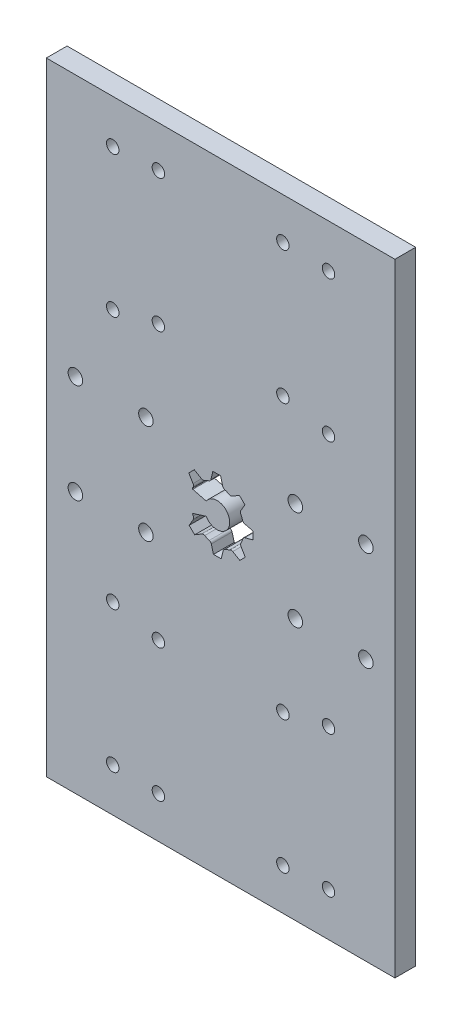
from build123d import *

# Parameters (mm, degrees)
CROQUIS1_W              = 84
CROQUIS1_H              = 150
CROQUIS1_R              = 1.5
CROQUIS1_R_2            = 1.75
SALIENTE_EXTRUIR1_DEPTH = 5


with BuildPart() as part:
    # Croquis1 → Saliente-Extruir1 (new body)
    with BuildSketch(Plane.XY):
        with Locations((42, 75)):
            Rectangle(CROQUIS1_W, CROQUIS1_H)
        with Locations((27, 108)):
            Circle(CROQUIS1_R, mode=Mode.SUBTRACT)
        with Locations((57, 108)):
            Circle(CROQUIS1_R, mode=Mode.SUBTRACT)
        with Locations((16, 139.5)):
            Circle(CROQUIS1_R, mode=Mode.SUBTRACT)
        with Locations((16, 105.5)):
            Circle(CROQUIS1_R, mode=Mode.SUBTRACT)
        with Locations((68, 105.5)):
            Circle(CROQUIS1_R, mode=Mode.SUBTRACT)
        with Locations((68, 139.5)):
            Circle(CROQUIS1_R, mode=Mode.SUBTRACT)
        with Locations((68, 44.5)):
            Circle(CROQUIS1_R, mode=Mode.SUBTRACT)
        with Locations((68, 10.5)):
            Circle(CROQUIS1_R, mode=Mode.SUBTRACT)
        with Locations((16, 10.5)):
            Circle(CROQUIS1_R, mode=Mode.SUBTRACT)
        with Locations((16, 44.5)):
            Circle(CROQUIS1_R, mode=Mode.SUBTRACT)
        with Locations((7, 87)):
            Circle(CROQUIS1_R_2, mode=Mode.SUBTRACT)
        with Locations((24, 87)):
            Circle(CROQUIS1_R_2, mode=Mode.SUBTRACT)
        with Locations((24, 63)):
            Circle(CROQUIS1_R_2, mode=Mode.SUBTRACT)
        with Locations((7, 63)):
            Circle(CROQUIS1_R_2, mode=Mode.SUBTRACT)
        with Locations((60, 63)):
            Circle(CROQUIS1_R_2, mode=Mode.SUBTRACT)
        with Locations((60, 87)):
            Circle(CROQUIS1_R_2, mode=Mode.SUBTRACT)
        with Locations((77, 63)):
            Circle(CROQUIS1_R_2, mode=Mode.SUBTRACT)
        with Locations((77, 87)):
            Circle(CROQUIS1_R_2, mode=Mode.SUBTRACT)
        with Locations((27, 140)):
            Circle(CROQUIS1_R, mode=Mode.SUBTRACT)
        with Locations((57, 140)):
            Circle(CROQUIS1_R, mode=Mode.SUBTRACT)
        with Locations((57, 42)):
            Circle(CROQUIS1_R, mode=Mode.SUBTRACT)
        with Locations((27, 42)):
            Circle(CROQUIS1_R, mode=Mode.SUBTRACT)
        with Locations((57, 10)):
            Circle(CROQUIS1_R, mode=Mode.SUBTRACT)
        with Locations((27, 10)):
            Circle(CROQUIS1_R, mode=Mode.SUBTRACT)
        with BuildLine():
            Line((34.323343601, 80.561599107), (35.636741331, 81.897273116))
            Line((35.636741331, 81.897273116), (37.36006695, 80.894327587))
            ThreePointArc((37.36006695, 80.894327587), (37.710271658, 80.796713171), (38.063524454, 80.882645547))
            ThreePointArc((38.063524454, 80.882645547), (38.605161451, 81.142605955), (39.168546725, 81.351285335))
            ThreePointArc((39.168546725, 81.351285335), (39.475874806, 81.545505215), (39.649132657, 81.865120028))
            Line((39.649132657, 81.865120028), (40.126027071, 83.80117856))
            Line((40.126027071, 83.80117856), (41.999203662, 83.816930268))
            Line((41.999203662, 83.816930268), (42.508589309, 81.889165452))
            ThreePointArc((42.508589309, 81.889165452), (42.687197617, 81.572509513), (42.99774843, 81.38348543))
            ThreePointArc((42.99774843, 81.38348543), (43.564563391, 81.184310005), (44.110495542, 80.933495061))
            ThreePointArc((44.110495542, 80.933495061), (44.465143507, 80.853515486), (44.81365711, 80.957005486))
            Line((44.81365711, 80.957005486), (46.519872501, 81.988790329))
            Line((46.519872501, 81.988790329), (47.85554651, 80.675392598))
            Line((47.85554651, 80.675392598), (46.852600981, 78.952066979))
            ThreePointArc((46.852600981, 78.952066979), (46.754986565, 78.601862272), (46.840918941, 78.248609475))
            ThreePointArc((46.840918941, 78.248609475), (47.10087935, 77.706972479), (47.309558729, 77.143587205))
            ThreePointArc((47.309558729, 77.143587205), (47.503778609, 76.836259124), (47.823393422, 76.663001273))
            Line((47.823393422, 76.663001273), (49.759451954, 76.186106858))
            Line((49.759451954, 76.186106858), (49.775203662, 74.312930268))
            Line((49.775203662, 74.312930268), (47.847438846, 73.803544621))
            ThreePointArc((47.847438846, 73.803544621), (47.530782907, 73.624936313), (47.341758824, 73.3143855))
            ThreePointArc((47.341758824, 73.3143855), (47.142583399, 72.747570539), (46.891768456, 72.201638387))
            ThreePointArc((46.891768456, 72.201638387), (46.81178888, 71.846990422), (46.91527888, 71.49847682))
            Line((46.91527888, 71.49847682), (47.947063723, 69.792261428))
            Line((47.947063723, 69.792261428), (46.633665992, 68.456587419))
            Line((46.633665992, 68.456587419), (44.910340373, 69.459532948))
            ThreePointArc((44.910340373, 69.459532948), (44.560135666, 69.557147364), (44.206882869, 69.471214989))
            ThreePointArc((44.206882869, 69.471214989), (43.665245873, 69.21125458), (43.101860599, 69.002575201))
            ThreePointArc((43.101860599, 69.002575201), (42.794532518, 68.80835532), (42.621274667, 68.488740508))
            Line((42.621274667, 68.488740508), (42.144380253, 66.552681975))
            Line((42.144380253, 66.552681975), (40.271203662, 66.536930268))
            Line((40.271203662, 66.536930268), (39.761818015, 68.464695084))
            ThreePointArc((39.761818015, 68.464695084), (39.583209707, 68.781351023), (39.272658894, 68.970375105))
            ThreePointArc((39.272658894, 68.970375105), (38.705843933, 69.169550531), (38.159911781, 69.420365474))
            ThreePointArc((38.159911781, 69.420365474), (37.805263816, 69.500345049), (37.456750214, 69.396855049))
            Line((37.456750214, 69.396855049), (35.750534822, 68.365070207))
            Line((35.750534822, 68.365070207), (34.414860813, 69.678467937))
            Line((34.414860813, 69.678467937), (35.417806342, 71.401793556))
            ThreePointArc((35.417806342, 71.401793556), (35.515420758, 71.751998264), (35.429488383, 72.10525106))
            ThreePointArc((35.429488383, 72.10525106), (35.343451134, 72.270729543), (35.262211867, 72.438615571))
            ThreePointArc((35.262211867, 72.438615571), (35.261157414, 72.550478141), (35.344779164, 72.624786614))
            Line((35.344779164, 72.624786614), (38.519245985, 73.605484883))
            ThreePointArc((38.519245985, 73.605484883), (44.186794242, 75.155248619), (38.541839298, 76.785388052))
            Line((38.541839298, 76.785388052), (35.305805909, 77.629256147))
            ThreePointArc((35.305805909, 77.629256147), (35.21814086, 77.701438299), (35.216498552, 77.814984441))
            ThreePointArc((35.216498552, 77.814984441), (35.295133958, 77.984773898), (35.378638868, 78.152222148))
            ThreePointArc((35.378638868, 78.152222148), (35.458618444, 78.506870113), (35.355128443, 78.855383716))
            Line((35.355128443, 78.855383716), (34.323343601, 80.561599107))
        make_face(mode=Mode.SUBTRACT)
    extrude(amount=SALIENTE_EXTRUIR1_DEPTH)


solid = part.part
